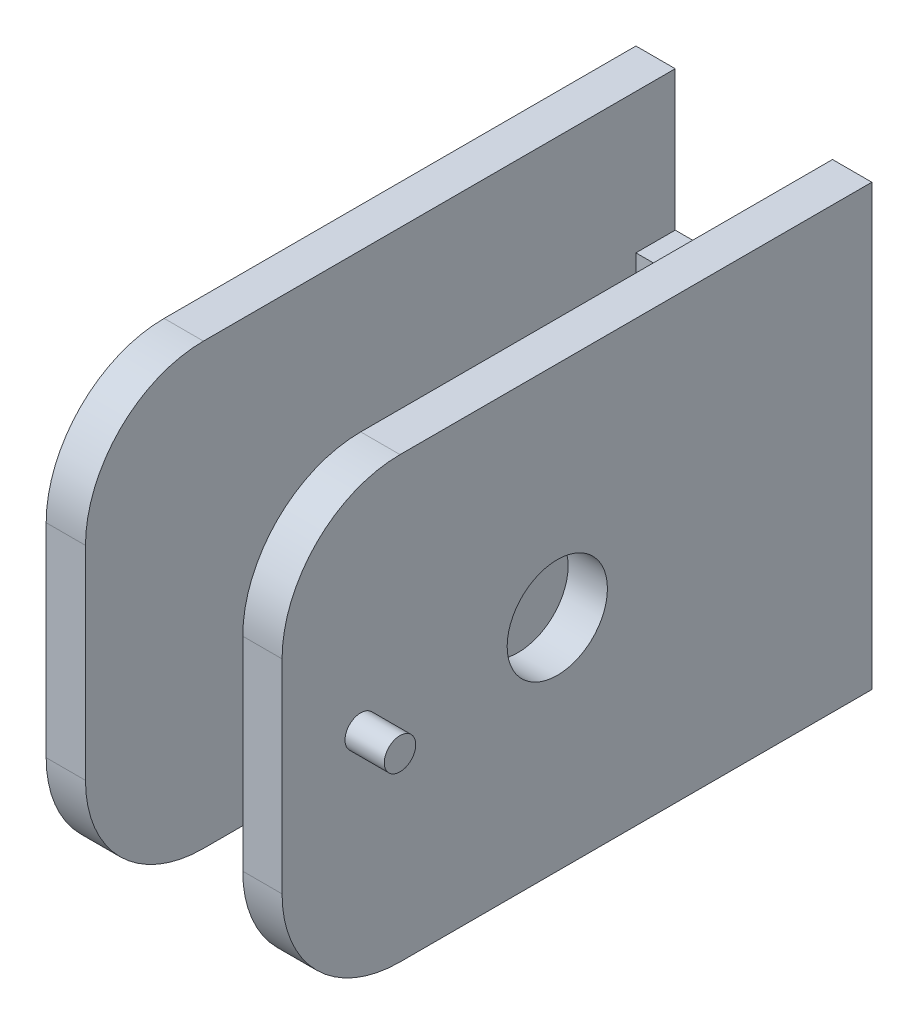
from build123d import *

# Parameters (mm, degrees)
BOSS_EXTRUDE1_DEPTH     = 13.97
SKETCH5_R               = 1
BOSS_EXTRUDE4_DEPTH     = 2.5
SKETCH6_W               = 10
SKETCH6_H               = 8.89
CUT_EXTRUDE1_DEPTH      = 2.5
FILLET1_R               = 7.5
SKETCH4_R               = 3.1877
CUT_EXTRUDE2_DEPTH      = 13.5
CUT_EXTRUDE2_DEPTH_BACK = 6


with BuildPart() as part:
    # Sketch1 → Boss-Extrude1 (new body, symmetric)
    with BuildSketch(Plane(origin=(0, 0, 0), x_dir=(1, 0, 0), z_dir=(0, 1, 0))):
        Polygon((-7.5, -17.5), (-7.5, 20), (7.5, 20), (7.5, -17.5), (5, -17.5), (5, 17.5), (-5, 17.5), (-5, -17.5), align=None)
    extrude(amount=BOSS_EXTRUDE1_DEPTH, both=True)

    # Sketch5 → Boss-Extrude4 (add)
    with BuildSketch(Plane(origin=(7.5, 0, 0), x_dir=(0, 0, -1), z_dir=(1, 0, 0))):
        with Locations((-12.5, 0)):
            Circle(SKETCH5_R)
    extrude(amount=BOSS_EXTRUDE4_DEPTH)

    # Sketch6 → Cut-Extrude1 (cut)
    with BuildSketch(Plane(origin=(0, 0, -20), x_dir=(-1, 0, 0), z_dir=(0, 0, -1))):
        with Locations((0, -9.525)):
            Rectangle(SKETCH6_W, SKETCH6_H)
    cut_extrude1 = extrude(amount=-CUT_EXTRUDE1_DEPTH, mode=Mode.SUBTRACT)

    # Fillet1
    fillet1_edges = [part.edges().sort_by_distance(p)[0] for p in [
        (6.25, -13.97, 17.5),
        (-6.25, 13.97, 17.5),
        (6.25, 13.97, 17.5),
        (-6.25, -13.97, 17.5),
    ]]
    fillet(fillet1_edges, radius=FILLET1_R)

    # Sketch4 → Cut-Extrude2 (cut, two sides)
    with BuildSketch(Plane.ZY.offset(-5)) as cut_extrude2_sk:
        Circle(SKETCH4_R)
    extrude(amount=CUT_EXTRUDE2_DEPTH, mode=Mode.SUBTRACT)
    extrude(cut_extrude2_sk.sketch, amount=-CUT_EXTRUDE2_DEPTH_BACK, mode=Mode.SUBTRACT)

    # Mirror2: Cut-Extrude1 across plane
    add(cut_extrude1.mirror(Plane.ZX), mode=Mode.SUBTRACT)


solid = part.part
